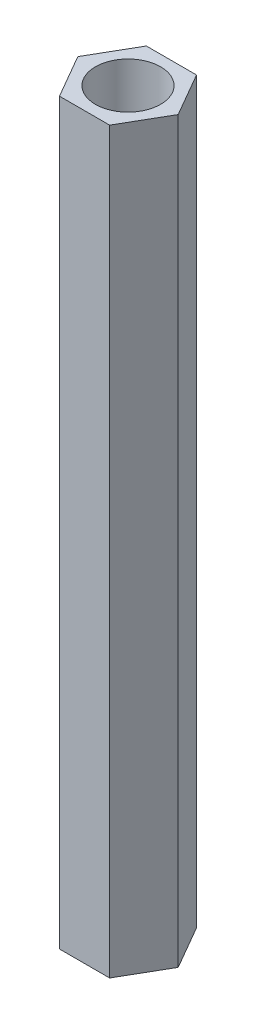
from build123d import *

# Parameters (mm, degrees)
CROQUIS1_R              = 1.5
SALIENTE_EXTRUIR1_DEPTH = 17


with BuildPart() as part:
    # Croquis1 → Saliente-Extruir1 (new body, symmetric)
    with BuildSketch(Plane(origin=(0, 0, 0), x_dir=(1, 0, 0), z_dir=(0, 1, 0))):
        Polygon((1.154700538, 2), (-1.154700538, 2), (-2.309401077, 0), (-1.154700538, -2), (1.154700538, -2), (2.309401077, 0), align=None)
        Circle(CROQUIS1_R, mode=Mode.SUBTRACT)
    extrude(amount=SALIENTE_EXTRUIR1_DEPTH, both=True)


solid = part.part
